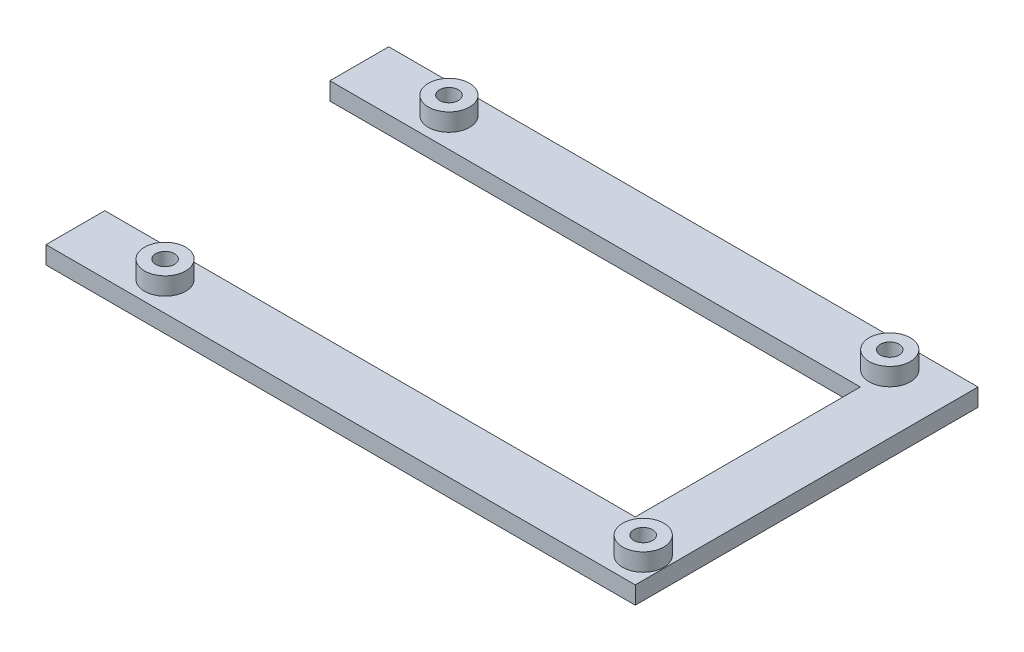
from build123d import *

# Parameters (mm, degrees)
SKETCH1_R           = 1.6
BOSS_EXTRUDE1_DEPTH = 3
SKETCH2_R           = 3.5
SKETCH2_R_2         = 1.6
BOSS_EXTRUDE2_DEPTH = 3


with BuildPart() as part:
    # Sketch1 → Boss-Extrude1 (new body)
    with BuildSketch(Plane(origin=(0, 0, 0), x_dir=(1, 0, 0), z_dir=(0, 1, 0))):
        Polygon((0, 7.54), (90.17, 7.54), (90.17, 45.8), (0, 45.8), (0, 55.8), (100.17, 55.8), (100.17, -2.46), (0, -2.46), align=None)
        with Locations((15.24, 2.54)):
            Circle(SKETCH1_R, mode=Mode.SUBTRACT)
        with Locations((96.52, 2.54)):
            Circle(SKETCH1_R, mode=Mode.SUBTRACT)
        with Locations((15.24, 50.8)):
            Circle(SKETCH1_R, mode=Mode.SUBTRACT)
        with Locations((90.17, 50.8)):
            Circle(SKETCH1_R, mode=Mode.SUBTRACT)
    extrude(amount=BOSS_EXTRUDE1_DEPTH)

    # Sketch2 → Boss-Extrude2 (add)
    with BuildSketch(Plane(origin=(0, 3, 0), x_dir=(1, 0, 0), z_dir=(0, 1, 0))):
        with Locations((15.24, 50.8)):
            Circle(SKETCH2_R)
        with Locations((15.24, 50.8)):
            Circle(SKETCH2_R_2, mode=Mode.SUBTRACT)
        with Locations((90.17, 50.8)):
            Circle(SKETCH2_R)
        with Locations((90.17, 50.8)):
            Circle(SKETCH2_R_2, mode=Mode.SUBTRACT)
        with Locations((96.52, 2.54)):
            Circle(SKETCH2_R)
        with Locations((96.52, 2.54)):
            Circle(SKETCH2_R_2, mode=Mode.SUBTRACT)
        with Locations((15.24, 2.54)):
            Circle(SKETCH2_R)
        with Locations((15.24, 2.54)):
            Circle(SKETCH2_R_2, mode=Mode.SUBTRACT)
    extrude(amount=BOSS_EXTRUDE2_DEPTH)


solid = part.part
